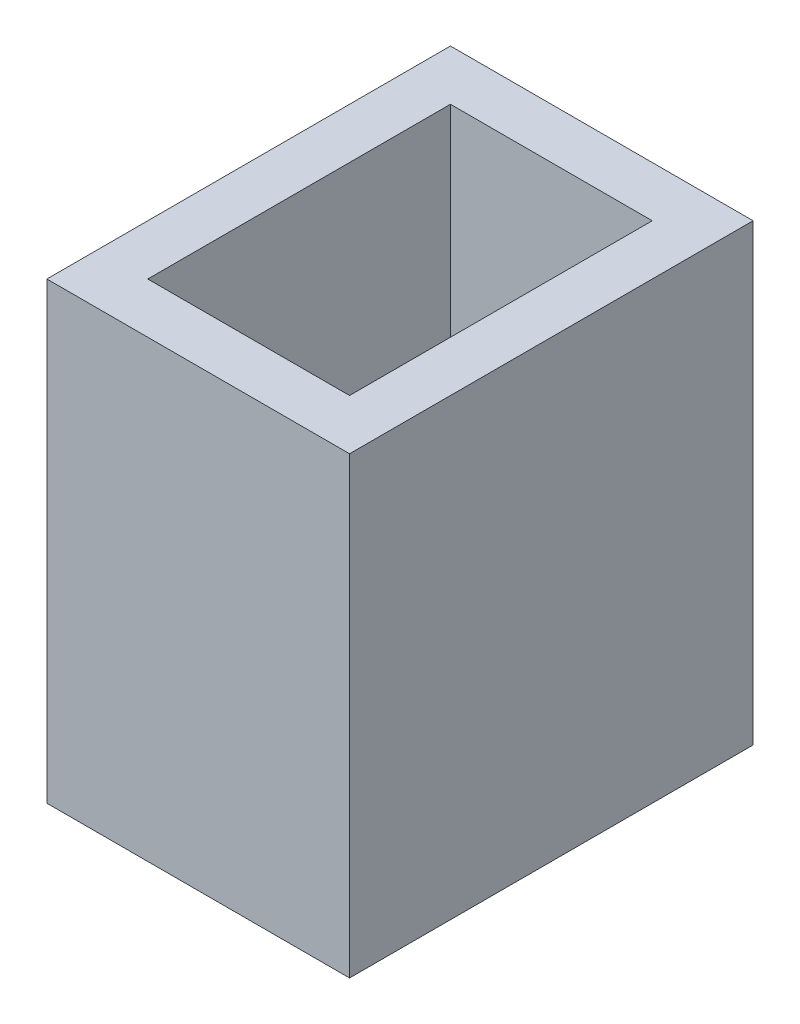
from build123d import *

# Parameters (mm, degrees)
SKETCH1_W           = 12
SKETCH1_H           = 16
BOSS_EXTRUDE1_DEPTH = 18
SHELL1_T            = -2
SKETCH2_R           = 0.75
CUT_EXTRUDE1_DEPTH  = 10


with BuildPart() as part:
    # Sketch1 → Boss-Extrude1 (new body)
    with BuildSketch(Plane(origin=(0, 0, 0), x_dir=(1, 0, 0), z_dir=(0, 1, 0))):
        with Locations((6, 8)):
            Rectangle(SKETCH1_W, SKETCH1_H)
    extrude(amount=BOSS_EXTRUDE1_DEPTH)

    # Shell1
    shell1_openings = [part.faces().sort_by_distance(p)[0] for p in [
        (6, 18, -8),
    ]]
    offset(amount=SHELL1_T, openings=shell1_openings, kind=Kind.INTERSECTION)

    # Sketch2 → Cut-Extrude1 (cut)
    with BuildSketch(Plane.XZ):
        with Locations((4.770114722, -4.163836206)):
            Circle(SKETCH2_R)
        with Locations((4.770114722, -6.703836206)):
            Circle(SKETCH2_R)
        with Locations((4.770114721, -11.783836206)):
            Circle(SKETCH2_R)
    extrude(amount=-CUT_EXTRUDE1_DEPTH, mode=Mode.SUBTRACT)


solid = part.part
